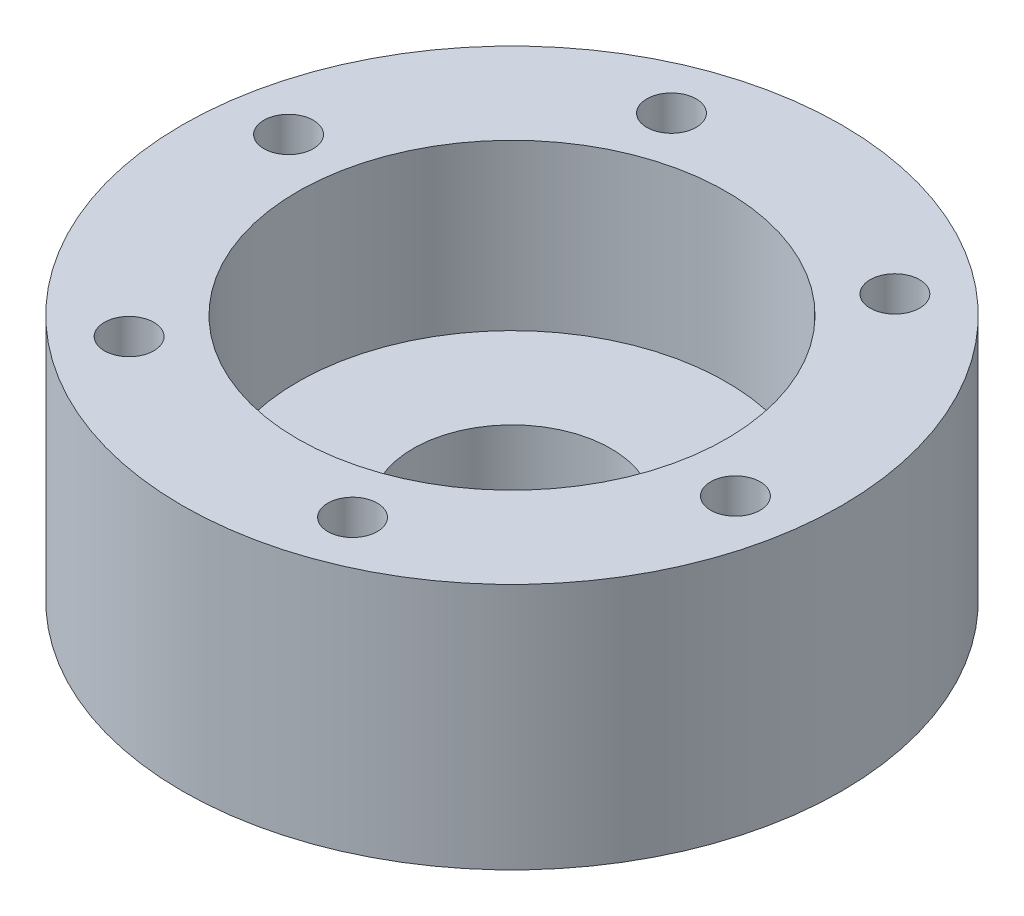
from build123d import *

# Parameters (mm, degrees)
SKETCH1_R           = 20
BOSS_EXTRUDE1_DEPTH = 15
SKETCH2_R           = 13
CUT_EXTRUDE1_DEPTH  = 10
SKETCH3_R           = 6
CUT_EXTRUDE2_DEPTH  = 5
SKETCH4_R           = 1.5
CUT_EXTRUDE3_DEPTH  = 15


with BuildPart() as part:
    # Sketch1 → Boss-Extrude1 (new body)
    with BuildSketch(Plane(origin=(0, 0, 0), x_dir=(1, 0, 0), z_dir=(0, 1, 0))):
        Circle(SKETCH1_R)
    extrude(amount=BOSS_EXTRUDE1_DEPTH)

    # Sketch2 → Cut-Extrude1 (cut)
    with BuildSketch(Plane(origin=(0, 15, 0), x_dir=(1, 0, 0), z_dir=(0, 1, 0))):
        Circle(SKETCH2_R)
    extrude(amount=-CUT_EXTRUDE1_DEPTH, mode=Mode.SUBTRACT)

    # Sketch3 → Cut-Extrude2 (cut)
    with BuildSketch(Plane(origin=(0, 5, 0), x_dir=(1, 0, 0), z_dir=(0, 1, 0))):
        Circle(SKETCH3_R)
    extrude(amount=-CUT_EXTRUDE2_DEPTH, mode=Mode.SUBTRACT)

    # Sketch4 → Cut-Extrude3 (cut)
    with BuildSketch(Plane(origin=(0, 15, 0), x_dir=(1, 0, 0), z_dir=(0, 1, 0))):
        with Locations((-10.493132047, -12.733584721)):
            Circle(SKETCH4_R)
        with Locations((-16.274173873, 2.720526557)):
            Circle(SKETCH4_R)
        with Locations((-5.781041827, 15.454111278)):
            Circle(SKETCH4_R)
        with Locations((10.493132047, 12.733584721)):
            Circle(SKETCH4_R)
        with Locations((16.274173873, -2.720526557)):
            Circle(SKETCH4_R)
        with Locations((5.781041827, -15.454111278)):
            Circle(SKETCH4_R)
    extrude(amount=-CUT_EXTRUDE3_DEPTH, mode=Mode.SUBTRACT)


solid = part.part
